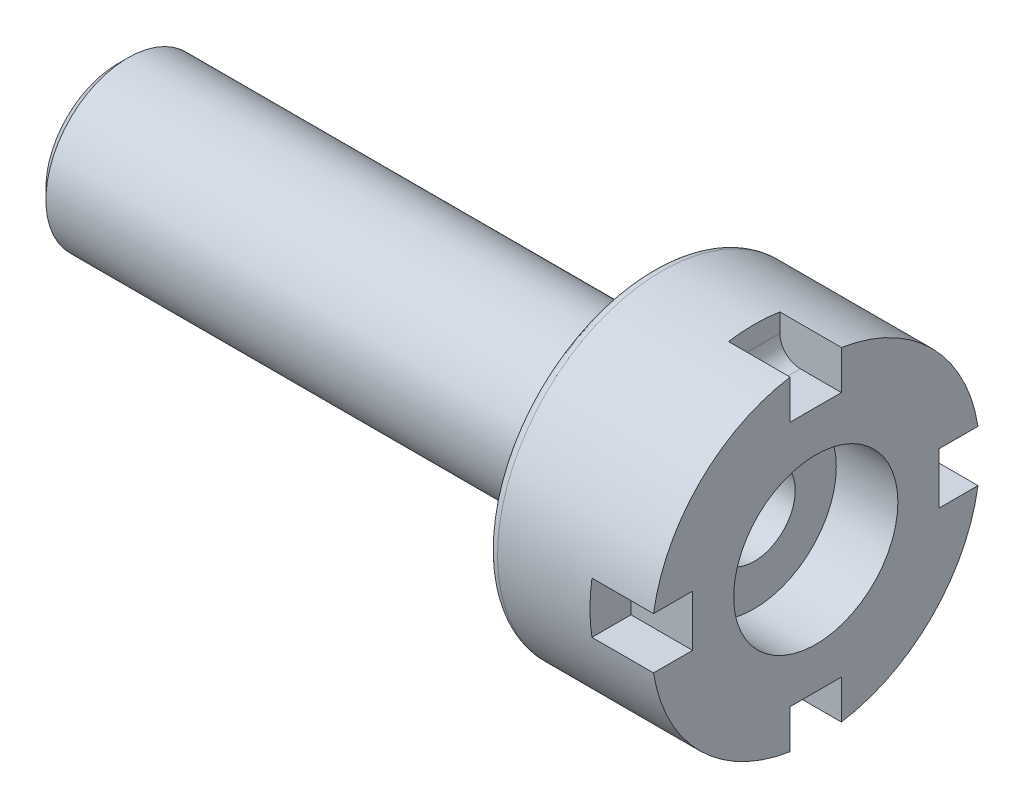
from build123d import *

# Parameters (mm, degrees)
SZKIC3_R                   = 40
SZKIC3_W                   = 25
SZKIC3_H                   = 30
WYTNIJ_WYCI_GNI_CIE1_DEPTH = 30
ZAOKR_GLENIE1_R            = 10
SZYK_KO_OWY1_COUNT         = 4
ZAOKR_GLENIE2_R            = 5
SFAZOWANIE2_SIZE           = 5


with BuildPart() as part:
    # Szkic2 → Obrót1 (revolve)
    with BuildSketch(Plane.XY):
        Polygon((-293.485716032, 20), (46.514283968, 20), (46.514283968, 80), (-33.485716032, 80), (-33.485716032, 40), (-293.485716032, 40), align=None)
    revolve(axis=Axis((-88.99, 0, 0), (1, 0, 0)))

    # Szkic3 → Wytnij-wyciągnięcie1 (cut)
    with BuildSketch(Plane(origin=(46.514283968, 0, 0), x_dir=(0, 0, -1), z_dir=(1, 0, 0))):
        Circle(SZKIC3_R)
        with Locations((0, 75)):
            Rectangle(SZKIC3_W, SZKIC3_H)
    wytnij_wyci_gni_cie1 = extrude(amount=-WYTNIJ_WYCI_GNI_CIE1_DEPTH, mode=Mode.SUBTRACT)

    # Zaokrąglenie1
    zaokr_glenie1_edges = [part.edges().sort_by_distance(p)[0] for p in [
        (16.514283968, 60, 0),
    ]]
    fillet(zaokr_glenie1_edges, radius=ZAOKR_GLENIE1_R)

    # Szyk kołowy1: Wytnij-wyciągnięcie1 ×4 about axis
    szyk_ko_owy1_axis = Axis((0, 0, 0), (1, 0, 0))
    for i in range(1, SZYK_KO_OWY1_COUNT):
        add(wytnij_wyci_gni_cie1.rotate(szyk_ko_owy1_axis, i * 360 / SZYK_KO_OWY1_COUNT), mode=Mode.SUBTRACT)

    # Zaokrąglenie2
    zaokr_glenie2_edges = [part.edges().sort_by_distance(p)[0] for p in [
        (-33.485716032, -40, 0),
        (-33.485716032, -80, 0),
    ]]
    fillet(zaokr_glenie2_edges, radius=ZAOKR_GLENIE2_R)

    # Sfazowanie2
    sfazowanie2_edges = [part.edges().sort_by_distance(p)[0] for p in [
        (-293.485716032, -40, 0),
        (-293.485716032, -20, 0),
    ]]
    chamfer(sfazowanie2_edges, length=SFAZOWANIE2_SIZE)


solid = part.part
